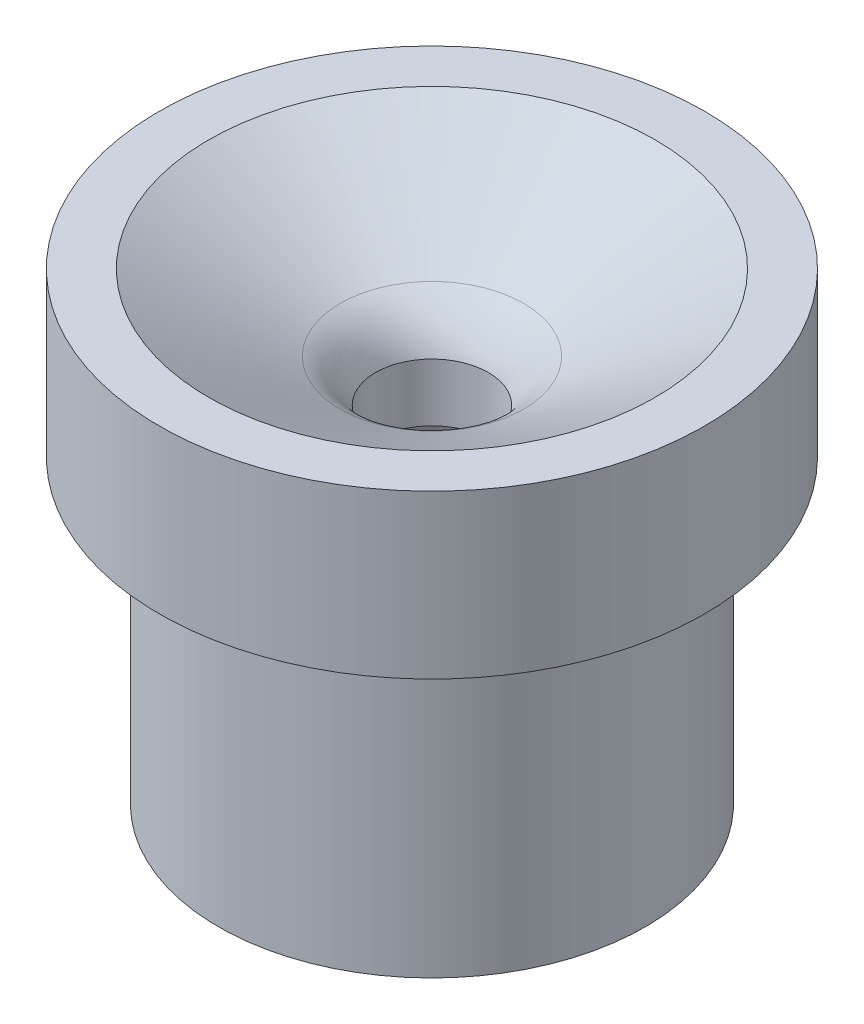
from build123d import *

# Parameters (mm, degrees)
SKETCH2_R          = 6.7183
CUT_EXTRUDE1_DEPTH = 56.211877571


with BuildPart() as part:
    # Sketch1 → Revolve1 (revolve)
    with BuildSketch(Plane.XY):
        with BuildLine():
            Line((-6.1595, 0), (-6.1595, 1.5875))
            ThreePointArc((-6.1595, 1.5875), (-7.435608029, 6.35), (-10.922, 9.836391971))
            Line((-10.922, 9.836391971), (-26.5811, 18.877177571))
            Line((-26.5811, 18.877177571), (-32.4739, 18.877177571))
            Line((-32.4739, 18.877177571), (-32.4739, -0.503022429))
            Line((-32.4739, -0.503022429), (-25.4, -0.503022429))
            Line((-25.4, -0.503022429), (-25.4, -36.3347))
            Line((-25.4, -36.3347), (-15.895353522, -36.3347))
            Line((-15.895353522, -36.3347), (-6.1595, 0))
        make_face()
    revolve(axis=Axis((0, 0, 0), (0, 1, 0)))

    # Sketch2 → Cut-Extrude1 (cut, through all)
    with BuildSketch(Plane(origin=(0, 18.877177571, 0), x_dir=(1, 0, 0), z_dir=(0, 1, 0))):
        Circle(SKETCH2_R)
    extrude(amount=-CUT_EXTRUDE1_DEPTH, mode=Mode.SUBTRACT)


solid = part.part
